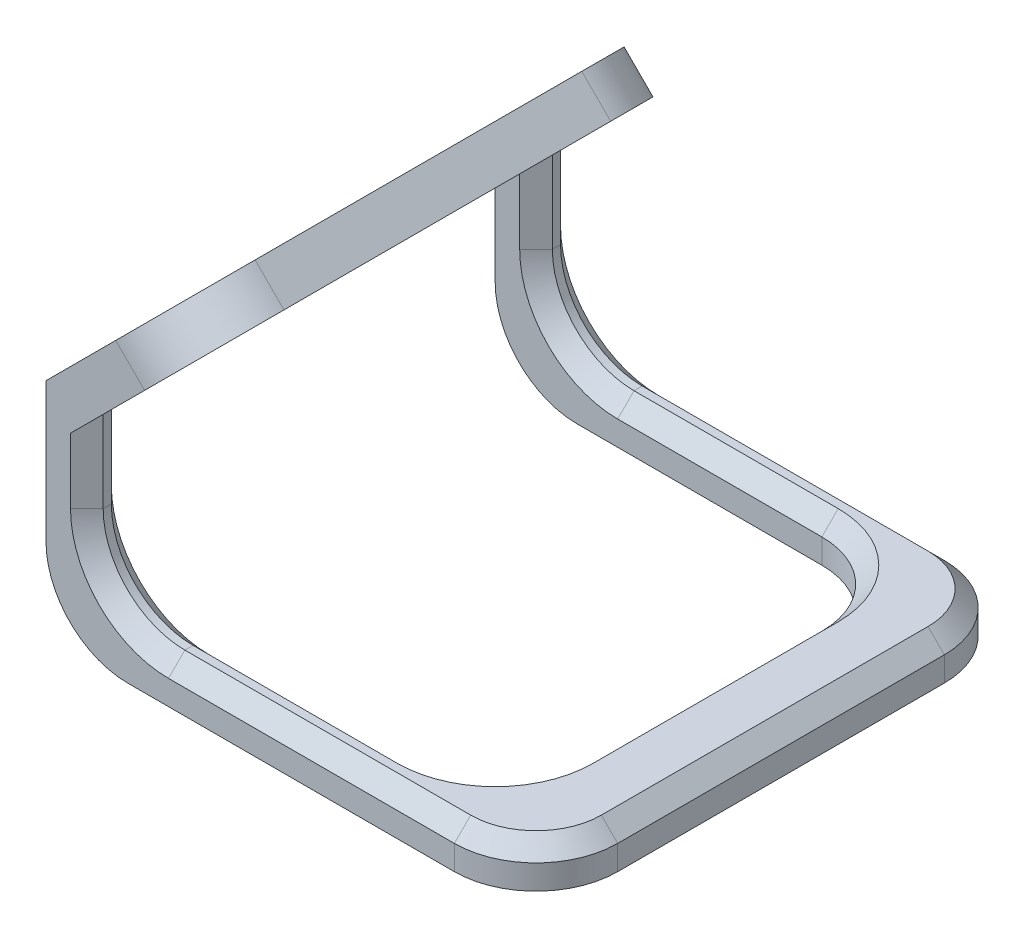
from build123d import *

# Parameters (mm, degrees)
BOSS_EXTRUDE1_DEPTH = 60
SKETCH2_W           = 50
SKETCH2_H           = 27.071067812
CUT_EXTRUDE1_DEPTH  = 50
FILLET1_R           = 10
CHAMFER1_SIZE       = 2
SKETCH3_R           = 2
CUT_EXTRUDE2_DEPTH  = 30
CHAMFER2_SIZE       = 5
CHAMFER2_SIZE2      = 3.535533906


with BuildPart() as part:
    # Sketch1 → Boss-Extrude1 (new body)
    with BuildSketch(Plane.XY):
        Polygon((0, 0), (-60, 0), (-60, 27.071067812), (-44.393398282, 42.67766953), (-40.857864376, 39.142135624), (-55, 25), (-55, 5), (0, 5), align=None)
    extrude(amount=BOSS_EXTRUDE1_DEPTH)

    # Sketch2 → Cut-Extrude1 (cut)
    with BuildSketch(Plane.ZY.offset(60)):
        with Locations((30, 13.535533906)):
            Rectangle(SKETCH2_W, SKETCH2_H)
    extrude(amount=-CUT_EXTRUDE1_DEPTH, mode=Mode.SUBTRACT)

    # Fillet1
    fillet1_edges = [part.edges().sort_by_distance(p)[0] for p in [
        (0, 2.5, 60),
        (-55, 5, 57.5),
        (-60, 0, 57.5),
        (-42.625631329, 40.909902577, 60),
        (-55, 5, 2.5),
        (-60, 0, 2.5),
        (-10, 2.5, 5),
        (-10, 2.5, 55),
        (-42.625631329, 40.909902577, 0),
        (0, 2.5, 0),
    ]]
    fillet(fillet1_edges, radius=FILLET1_R)

    # Chamfer1
    chamfer1_edges = [part.edges().sort_by_distance(p)[0] for p in [
        (-55, 20, 5),
        (-10, 5, 30),
        (-32.5, 5, 5),
        (-55, 20, 55),
        (-32.5, 5, 55),
        (-55, 20, 0),
        (-27.5, 5, 0),
        (-27.5, 5, 60),
        (-55, 20, 60),
        (0, 5, 30),
        (-2.928932188, 5, 57.071067812),
        (-2.928932188, 5, 2.928932188),
        (-12.928932188, 5, 7.928932188),
        (-12.928932188, 5, 52.071067812),
        (-52.071067812, 7.928932188, 0),
        (-52.071067812, 7.928932188, 5),
        (-52.071067812, 7.928932188, 55),
        (-52.071067812, 7.928932188, 60),
    ]]
    chamfer(chamfer1_edges, length=CHAMFER1_SIZE)

    # Sketch3 → Cut-Extrude2 (cut)
    with BuildSketch(Plane(origin=(-43.535533906, 43.535533906, 0), x_dir=(0, 0, 1), z_dir=(-0.7071067811865464, 0.7071067811865488, 0))):
        with Locations(Location((30, -6.284271247, 0), (0, 0, 270))):
            Circle(SKETCH3_R)
        with Locations(Location((36, -12.284271247, 0), (0, 0, 270))):
            Circle(SKETCH3_R)
        with Locations(Location((24, -12.284271247, 0), (0, 0, 270))):
            Circle(SKETCH3_R)
        with Locations(Location((18, -6.284271247, 0), (0, 0, 270))):
            Circle(SKETCH3_R)
        with Locations(Location((12, -12.284271247, 0), (0, 0, 270))):
            Circle(SKETCH3_R)
        with Locations(Location((42, -6.284271247, 0), (0, 0, 270))):
            Circle(SKETCH3_R)
        with Locations(Location((48, -12.284271247, 0), (0, 0, 270))):
            Circle(SKETCH3_R)
    extrude(amount=-CUT_EXTRUDE2_DEPTH, mode=Mode.SUBTRACT)

    # Chamfer2
    chamfer2_edges = [part.edges().sort_by_distance(p)[0] for p in [
        (-60, 27.071067812, 30),
    ]]
    chamfer2_side = [part.faces().sort_by_distance(p)[0] for p in [
        (-52.552716381, 34.518351431, 30),
    ]]
    chamfer(chamfer2_edges, length=CHAMFER2_SIZE, length2=CHAMFER2_SIZE2, reference=chamfer2_side[0])


solid = part.part
